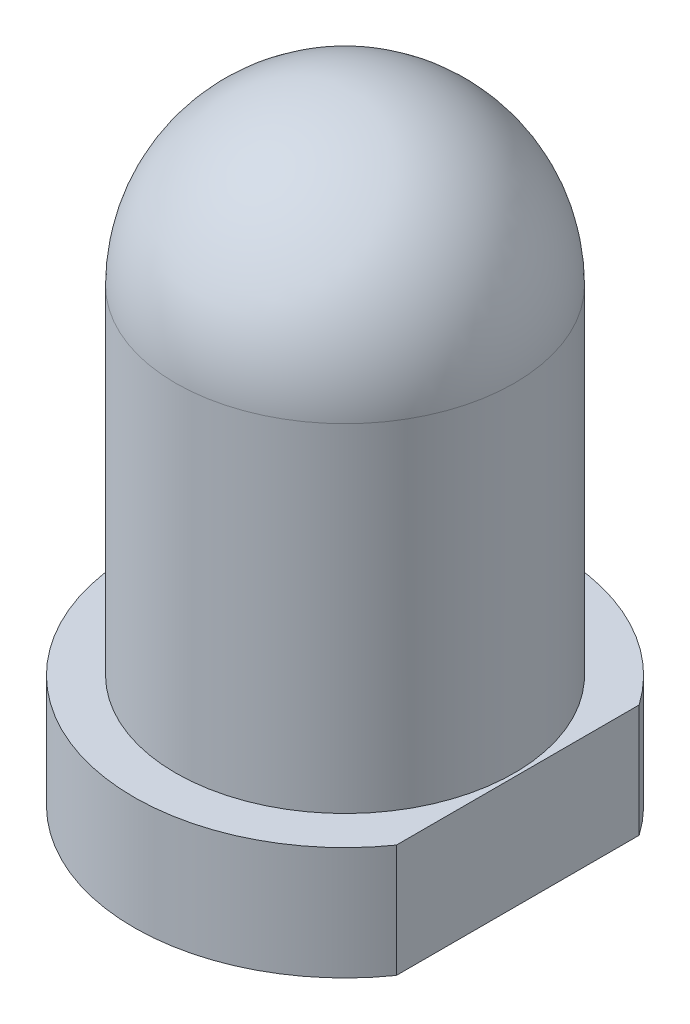
from build123d import *

# Parameters (mm, degrees)
SKETCH1_R           = 1.87
BOSS_EXTRUDE1_DEPTH = 1
SKETCH6_W           = 0.679962926
SKETCH6_H           = 3.014349716
CUT_EXTRUDE1_DEPTH  = 1


with BuildPart() as part:
    # Sketch1 → Boss-Extrude1 (new body)
    with BuildSketch(Plane(origin=(0, 0, 0), x_dir=(1, 0, 0), z_dir=(0, 1, 0))):
        Circle(SKETCH1_R)
    extrude(amount=BOSS_EXTRUDE1_DEPTH)

    # Sketch3 → Revolve2 (revolve)
    with BuildSketch(Plane.XY):
        with BuildLine():
            Line((1.5, 3.99), (1.5, 1))
            Line((1.5, 1), (0, 1))
            Line((0, 1), (0, 5.49))
            ThreePointArc((0, 5.49), (1.060660172, 5.050660172), (1.5, 3.99))
        make_face()
    revolve(axis=Axis((0, 5.49, 0), (0, -1, 0)))

    # Sketch6 → Cut-Extrude1 (cut)
    with BuildSketch(Plane(origin=(0, 1, 0), x_dir=(1, 0, 0), z_dir=(0, 1, 0))):
        with Locations((1.87, 0)):
            Rectangle(SKETCH6_W, SKETCH6_H)
    extrude(amount=-CUT_EXTRUDE1_DEPTH, mode=Mode.SUBTRACT)


solid = part.part
